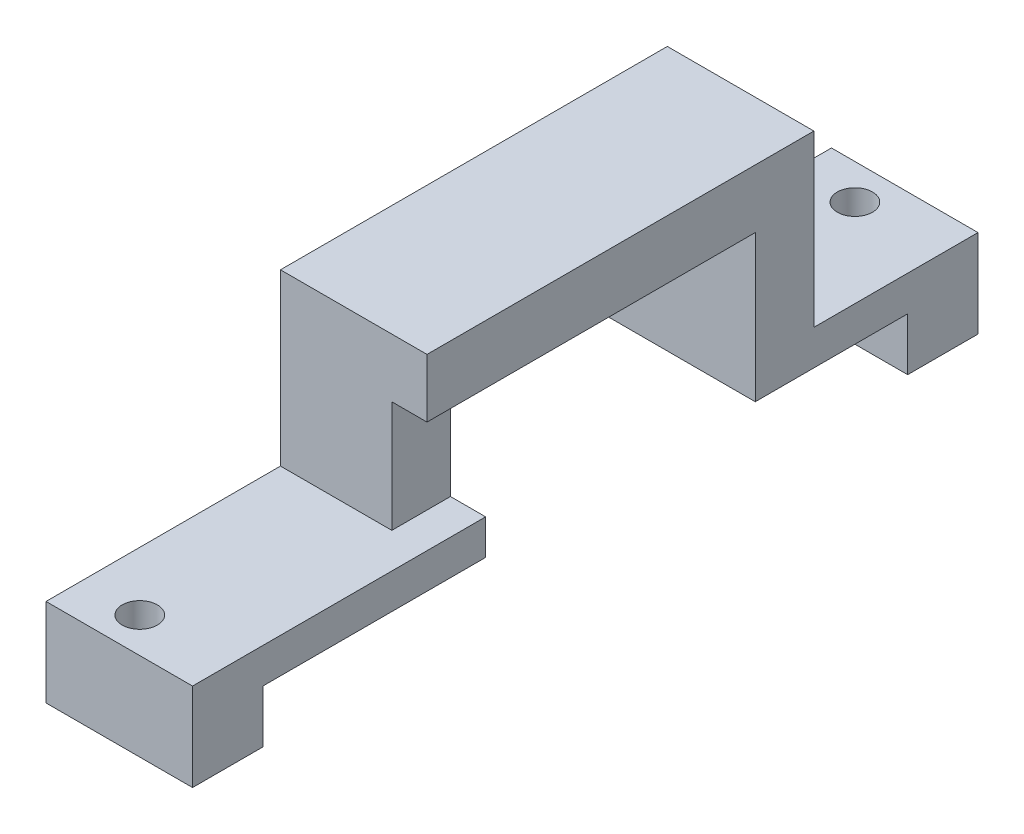
from build123d import *

# Parameters (mm, degrees)
BOSS_EXTRUDE1_DEPTH = 12.5
SKETCH3_R           = 1.5
CUT_EXTRUDE1_DEPTH  = 12.5
SKETCH4_W           = 3
SKETCH4_H           = 9.5
CUT_EXTRUDE2_DEPTH  = 5
SKETCH5_W           = 80.755036426
SKETCH5_H           = 34.070446291
CUT_EXTRUDE3_DEPTH  = 29.5
SKETCH6_R           = 1
CUT_EXTRUDE5_DEPTH  = 3


with BuildPart() as part:
    # Sketch2 → Boss-Extrude1 (new body)
    with BuildSketch(Plane(origin=(0, 0, 0), x_dir=(0, 0, -1), z_dir=(1, 0, 0))):
        Polygon((6, 0), (25, 0), (25, 12.5), (48, 12.5), (48, 0), (61, 0), (61, -4.5), (67, -4.5), (67, 0), (67, 3), (53, 3), (53, 17.5), (20, 17.5), (20, 3), (0, 3), (0, 0), (0, -4.5), (6, -4.5), align=None)
    extrude(amount=BOSS_EXTRUDE1_DEPTH)

    # Sketch3 → Cut-Extrude1 (cut)
    with BuildSketch(Plane(origin=(0, 3, 0), x_dir=(1, 0, 0), z_dir=(0, 1, 0))):
        with Locations((7.5, 3)):
            Circle(SKETCH3_R)
        with Locations((7.5, 64)):
            Circle(SKETCH3_R)
    extrude(amount=-CUT_EXTRUDE1_DEPTH, mode=Mode.SUBTRACT)

    # Sketch4 → Cut-Extrude2 (cut)
    with BuildSketch(Plane.XY.offset(-20)):
        with Locations((1.5, 7.75)):
            Rectangle(SKETCH4_W, SKETCH4_H)
    extrude(amount=-CUT_EXTRUDE2_DEPTH, mode=Mode.SUBTRACT)

    # Mirror1: part across plane


with BuildPart() as part_1:
    add(part.part)
    add(part.part.mirror(Plane(origin=(0, 0, 0), x_dir=(0, 0, 1), z_dir=(1, 0, 0))))

    # Sketch5 → Cut-Extrude3 (cut)
    with BuildSketch(Plane(origin=(0, 0, 0), x_dir=(0, 0, -1), z_dir=(1, 0, 0))):
        with Locations((38.216510399, 1.156786657)):
            Rectangle(SKETCH5_W, SKETCH5_H)
    extrude(amount=CUT_EXTRUDE3_DEPTH, mode=Mode.SUBTRACT)

    # Sketch6 → Cut-Extrude5 (cut)
    with BuildSketch(Plane.ZY.offset(12.5)):
        with Locations((-50.35, 6.25)):
            Circle(SKETCH6_R)
        with Locations((-22.65, 6.25)):
            Circle(SKETCH6_R)
    extrude(amount=-CUT_EXTRUDE5_DEPTH, mode=Mode.SUBTRACT)


solid = part_1.part
